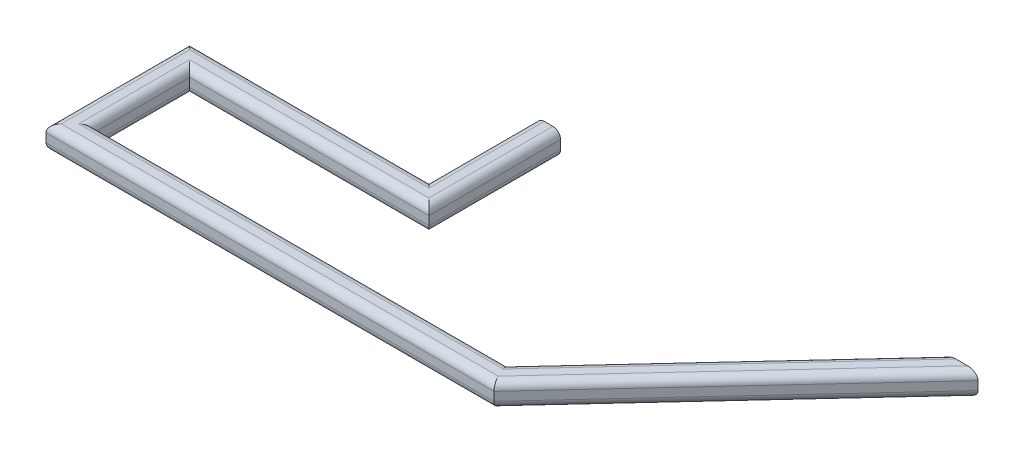
from build123d import *

# Parameters (mm, degrees)
SKETCH11_W         = 135.340286593
SKETCH11_H         = 57.113739626
CUT_EXTRUDE1_DEPTH = 18.6646359


with BuildPart() as part:
    # Sweep-Thin1: sweep along a path in Sketch2
    with BuildLine(Plane(origin=(0, 0, 0), x_dir=(1, 0, 0), z_dir=(0, 1, 0))) as sweep_thin1_path:
        Line((439.99296617, 259.17166973), (431.5, 250))
        Line((431.5, 250), (200, 0))
        Line((200, 0), (0, 0))
        Line((0, 0), (-250, 0))
        Line((-250, 0), (-250, 125))
        Line((-250, 125), (0, 125))
        Line((0, 125), (0, 250))
    # Sketch6 → Sweep-Thin1 (sweep)
    with BuildSketch(Plane.XY.offset(-250)):
        with BuildLine():
            Line((4.5, 12.5), (-4.5, 12.5))
            ThreePointArc((-4.5, 12.5), (-10.156854249, 10.156854249), (-12.5, 4.5))
            Line((-12.5, 4.5), (-12.5, -4.5))
            ThreePointArc((-12.5, -4.5), (-10.156854249, -10.156854249), (-4.5, -12.5))
            Line((-4.5, -12.5), (4.5, -12.5))
            ThreePointArc((4.5, -12.5), (10.156854249, -10.156854249), (12.5, -4.5))
            Line((12.5, -4.5), (12.5, 4.5))
            ThreePointArc((12.5, 4.5), (10.156854249, 10.156854249), (4.5, 12.5))
        make_face()
        with BuildLine():
            Line((4.5, 9.5), (-4.5, 9.5))
            ThreePointArc((-4.5, 9.5), (-8.035533906, 8.035533906), (-9.5, 4.5))
            Line((-9.5, 4.5), (-9.5, -4.5))
            ThreePointArc((-9.5, -4.5), (-8.035533906, -8.035533906), (-4.5, -9.5))
            Line((-4.5, -9.5), (4.5, -9.5))
            ThreePointArc((4.5, -9.5), (8.035533906, -8.035533906), (9.5, -4.5))
            Line((9.5, -4.5), (9.5, 4.5))
            ThreePointArc((9.5, 4.5), (8.035533906, 8.035533906), (4.5, 9.5))
        make_face(mode=Mode.SUBTRACT)
    sweep(path=sweep_thin1_path.line, transition=Transition.RIGHT)

    # Sketch11 → Cut-Extrude1 (cut, through all)
    with BuildSketch(Plane.XY.offset(-250)):
        with Locations((387.319769347, 0)):
            Rectangle(SKETCH11_W, SKETCH11_H)
    extrude(amount=-CUT_EXTRUDE1_DEPTH, mode=Mode.SUBTRACT)


solid = part.part
